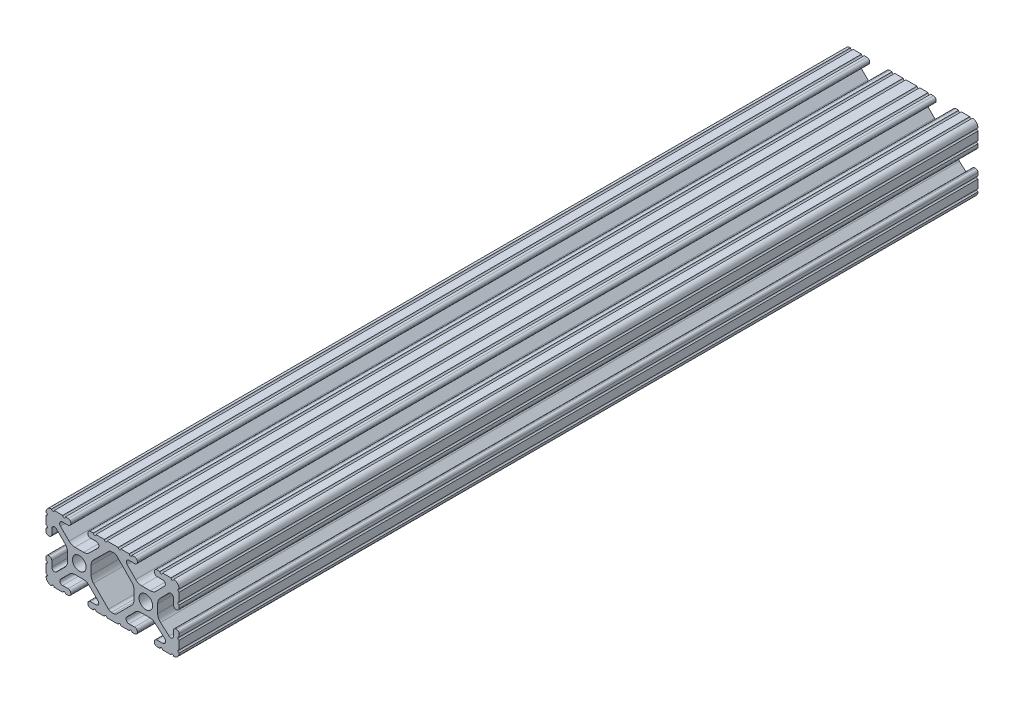
from build123d import *

# Parameters (mm, degrees)
SKETCH1_R           = 2.6035
BOSS_EXTRUDE1_DEPTH = 152.4


with BuildPart() as part:
    # Sketch1 → Boss-Extrude1 (new body, symmetric)
    with BuildSketch(Plane.XY):
        with BuildLine():
            Line((18.01710265, 12.7), (16.98745015, 12.7))
            ThreePointArc((16.98745015, 12.7), (16.245730386, 12.392769614), (15.9385, 11.65104985))
            Line((15.9385, 11.65104985), (15.9385, 11.53922))
            ThreePointArc((15.9385, 11.53922), (16.245750844, 10.797450844), (16.98752, 10.4902))
            Line((16.98752, 10.4902), (19.116384363, 10.4902))
            ThreePointArc((19.116384363, 10.4902), (20.052502933, 9.869096983), (19.844087081, 8.765172272))
            Line((19.844087081, 8.765172272), (16.618993479, 5.455112286))
            ThreePointArc((16.618993479, 5.455112286), (15.578994274, 4.745442459), (14.344932584, 4.4958))
            Line((14.344932584, 4.4958), (11.083317835, 4.4958))
            ThreePointArc((11.083317835, 4.4958), (9.854330953, 4.743306833), (8.816955189, 5.447238587))
            Line((8.816955189, 5.447238587), (5.564154119, 8.762652677))
            ThreePointArc((5.564154119, 8.762652677), (5.352591412, 9.867473037), (6.289393385, 10.4902))
            Line((6.289393385, 10.4902), (8.41248, 10.4902))
            ThreePointArc((8.41248, 10.4902), (9.154249156, 10.797450844), (9.4615, 11.53922))
            Line((9.4615, 11.53922), (9.4615, 11.65104985))
            ThreePointArc((9.4615, 11.65104985), (9.154269614, 12.392769614), (8.41254985, 12.7))
            Line((8.41254985, 12.7), (7.38288465, 12.7))
            ThreePointArc((7.38288465, 12.7), (6.87488465, 12.192), (6.36688465, 12.7))
            Line((6.36688465, 12.7), (3.14958095, 12.7))
            ThreePointArc((3.14958095, 12.7), (2.64158095, 12.192), (2.13358095, 12.7))
            Line((2.13358095, 12.7), (-2.13358095, 12.7))
            ThreePointArc((-2.13358095, 12.7), (-2.64158095, 12.192), (-3.14958095, 12.7))
            Line((-3.14958095, 12.7), (-6.36689735, 12.7))
            ThreePointArc((-6.36689735, 12.7), (-6.87489735, 12.192), (-7.38289735, 12.7))
            Line((-7.38289735, 12.7), (-8.41254985, 12.7))
            ThreePointArc((-8.41254985, 12.7), (-9.154269614, 12.392769614), (-9.4615, 11.65104985))
            Line((-9.4615, 11.65104985), (-9.4615, 11.53922))
            ThreePointArc((-9.4615, 11.53922), (-9.154249156, 10.797450844), (-8.41248, 10.4902))
            Line((-8.41248, 10.4902), (-6.283641037, 10.4902))
            ThreePointArc((-6.283641037, 10.4902), (-5.297291557, 9.829633109), (-5.532576693, 8.666071843))
            Line((-5.532576693, 8.666071843), (-8.809985098, 5.416263103))
            ThreePointArc((-8.809985098, 5.416263103), (-9.836720513, 4.734920264), (-11.045536121, 4.4958))
            Line((-11.045536121, 4.4958), (-14.354463879, 4.4958))
            ThreePointArc((-14.354463879, 4.4958), (-15.563279487, 4.734920264), (-16.590014902, 5.416263103))
            Line((-16.590014902, 5.416263103), (-19.867423307, 8.666071843))
            ThreePointArc((-19.867423307, 8.666071843), (-20.102708443, 9.829633109), (-19.116358963, 10.4902))
            Line((-19.116358963, 10.4902), (-16.98752, 10.4902))
            ThreePointArc((-16.98752, 10.4902), (-16.245750844, 10.797450844), (-15.9385, 11.53922))
            Line((-15.9385, 11.53922), (-15.9385, 11.65104985))
            ThreePointArc((-15.9385, 11.65104985), (-16.245730386, 12.392769614), (-16.98745015, 12.7))
            Line((-16.98745015, 12.7), (-18.01711535, 12.7))
            ThreePointArc((-18.01711535, 12.7), (-18.52511535, 12.192), (-19.03311535, 12.7))
            Line((-19.03311535, 12.7), (-22.2504, 12.7))
            ThreePointArc((-22.2504, 12.7), (-22.758323491, 12.192000006), (-23.266399977, 12.699846982))
            ThreePointArc((-23.266399977, 12.699846982), (-24.782522516, 12.082522516), (-25.399846982, 10.566399977))
            ThreePointArc((-25.399846982, 10.566399977), (-24.892000006, 10.058323491), (-25.4, 9.5504))
            Line((-25.4, 9.5504), (-25.4, 6.3330836))
            ThreePointArc((-25.4, 6.3330836), (-24.892, 5.8250836), (-25.4, 5.3170836))
            Line((-25.4, 5.3170836), (-25.4, 4.237520184))
            ThreePointArc((-25.4, 4.237520184), (-25.107393763, 3.531106237), (-24.400979816, 3.2385))
            Line((-24.400979816, 3.2385), (-24.23922, 3.2385))
            ThreePointArc((-24.23922, 3.2385), (-23.497450844, 3.545750844), (-23.1902, 4.28752))
            Line((-23.1902, 4.28752), (-23.1902, 6.334741132))
            ThreePointArc((-23.1902, 6.334741132), (-22.556026952, 7.286023527), (-21.434002553, 7.066535717))
            Line((-21.434002553, 7.066535717), (-18.147950853, 3.808156468))
            ThreePointArc((-18.147950853, 3.808156468), (-17.452759693, 2.774838327), (-17.208501877, 1.553619571))
            Line((-17.208501877, 1.553619571), (-17.208501877, -1.695179196))
            ThreePointArc((-17.208501877, -1.695179196), (-17.450738657, -2.911536421), (-18.140486065, -3.942289578))
            Line((-18.140486065, -3.942289578), (-21.431579576, -7.227386226))
            ThreePointArc((-21.431579576, -7.227386226), (-22.55444896, -7.449940594), (-23.1902, -6.498002195))
            Line((-23.1902, -6.498002195), (-23.1902, -4.28752))
            ThreePointArc((-23.1902, -4.28752), (-23.497450844, -3.545750844), (-24.23922, -3.2385))
            Line((-24.23922, -3.2385), (-24.35098, -3.2385))
            ThreePointArc((-24.35098, -3.2385), (-25.092749156, -3.545750844), (-25.4, -4.28752))
            Line((-25.4, -4.28752), (-25.4, -5.3171344))
            ThreePointArc((-25.4, -5.3171344), (-24.892, -5.8251344), (-25.4, -6.3331344))
            Line((-25.4, -6.3331344), (-25.4, -9.5504))
            ThreePointArc((-25.4, -9.5504), (-24.892000006, -10.058323491), (-25.399846982, -10.566399977))
            ThreePointArc((-25.399846982, -10.566399977), (-24.782522516, -12.082522516), (-23.266399977, -12.699846982))
            ThreePointArc((-23.266399977, -12.699846982), (-22.758323491, -12.192000006), (-22.2504, -12.7))
            Line((-22.2504, -12.7), (-19.03308995, -12.7))
            ThreePointArc((-19.03308995, -12.7), (-18.52508995, -12.192), (-18.01708995, -12.7))
            Line((-18.01708995, -12.7), (-16.9874692, -12.7))
            ThreePointArc((-16.9874692, -12.7), (-16.245700044, -12.392749156), (-15.9384492, -11.65098))
            Line((-15.9384492, -11.65098), (-15.9384492, -11.53922))
            ThreePointArc((-15.9384492, -11.53922), (-16.245700044, -10.797450844), (-16.9874692, -10.4902))
            Line((-16.9874692, -10.4902), (-19.116358963, -10.4902))
            ThreePointArc((-19.116358963, -10.4902), (-20.055197748, -9.862578342), (-19.834124023, -8.755124678))
            Line((-19.834124023, -8.755124678), (-16.49660751, -5.423689618))
            ThreePointArc((-16.49660751, -5.423689618), (-15.467274017, -4.736928798), (-14.253591699, -4.4958))
            Line((-14.253591699, -4.4958), (-11.146408301, -4.4958))
            ThreePointArc((-11.146408301, -4.4958), (-9.932725983, -4.736928798), (-8.90339249, -5.423689618))
            Line((-8.90339249, -5.423689618), (-5.565875977, -8.755124678))
            ThreePointArc((-5.565875977, -8.755124678), (-5.344802252, -9.862578342), (-6.283641037, -10.4902))
            Line((-6.283641037, -10.4902), (-8.4125308, -10.4902))
            ThreePointArc((-8.4125308, -10.4902), (-9.154299956, -10.797450844), (-9.4615508, -11.53922))
            Line((-9.4615508, -11.53922), (-9.4615508, -11.65098))
            ThreePointArc((-9.4615508, -11.65098), (-9.154299956, -12.392749156), (-8.4125308, -12.7))
            Line((-8.4125308, -12.7), (-7.38287195, -12.7))
            ThreePointArc((-7.38287195, -12.7), (-6.87487195, -12.192), (-6.36687195, -12.7))
            Line((-6.36687195, -12.7), (-3.14960635, -12.7))
            ThreePointArc((-3.14960635, -12.7), (-2.64160635, -12.192), (-2.13360635, -12.7))
            Line((-2.13360635, -12.7), (2.13360635, -12.7))
            ThreePointArc((2.13360635, -12.7), (2.64159365, -12.1920127), (3.14958095, -12.7))
            Line((3.14958095, -12.7), (6.36691005, -12.7))
            ThreePointArc((6.36691005, -12.7), (6.87491005, -12.192), (7.38291005, -12.7))
            Line((7.38291005, -12.7), (8.4125308, -12.7))
            ThreePointArc((8.4125308, -12.7), (9.154299956, -12.392749156), (9.4615508, -11.65098))
            Line((9.4615508, -11.65098), (9.4615508, -11.53922))
            ThreePointArc((9.4615508, -11.53922), (9.154299956, -10.797450844), (8.4125308, -10.4902))
            Line((8.4125308, -10.4902), (6.289393385, -10.4902))
            ThreePointArc((6.289393385, -10.4902), (5.231590322, -9.783049717), (5.480677245, -8.535265862))
            Line((5.480677245, -8.535265862), (8.597933595, -5.423689618))
            ThreePointArc((8.597933595, -5.423689618), (9.627267088, -4.736928798), (10.840949406, -4.4958))
            Line((10.840949406, -4.4958), (14.102564155, -4.4958))
            ThreePointArc((14.102564155, -4.4958), (15.215927525, -4.697410182), (16.187895372, -5.276636531))
            Line((16.187895372, -5.276636531), (19.868247549, -8.482246082))
            ThreePointArc((19.868247549, -8.482246082), (20.188435806, -9.746879864), (19.116384363, -10.4902))
            Line((19.116384363, -10.4902), (16.9874692, -10.4902))
            ThreePointArc((16.9874692, -10.4902), (16.245700044, -10.797450844), (15.9384492, -11.53922))
            Line((15.9384492, -11.53922), (15.9384492, -11.65098))
            ThreePointArc((15.9384492, -11.65098), (16.245700044, -12.392749156), (16.9874692, -12.7))
            Line((16.9874692, -12.7), (18.01710265, -12.7))
            ThreePointArc((18.01710265, -12.7), (18.52510265, -12.192), (19.03310265, -12.7))
            Line((19.03310265, -12.7), (22.2504, -12.7))
            ThreePointArc((22.2504, -12.7), (22.758323491, -12.192000006), (23.266399977, -12.699846982))
            ThreePointArc((23.266399977, -12.699846982), (24.782522516, -12.082522516), (25.399846982, -10.566399977))
            ThreePointArc((25.399846982, -10.566399977), (24.892000006, -10.058323492), (25.4, -9.550400001))
            Line((25.4, -9.550400001), (25.4, -6.333083592))
            ThreePointArc((25.4, -6.333083592), (24.892000001, -5.825083593), (25.4, -5.317083593))
            Line((25.4, -5.317083593), (25.4, -4.237520184))
            ThreePointArc((25.4, -4.237520184), (25.107393763, -3.531106237), (24.400979816, -3.2385))
            Line((24.400979816, -3.2385), (24.189220184, -3.2385))
            ThreePointArc((24.189220184, -3.2385), (23.482806237, -3.531106237), (23.1902, -4.237520184))
            Line((23.1902, -4.237520184), (23.1902, -6.155876159))
            ThreePointArc((23.1902, -6.155876159), (22.62232736, -7.038258539), (21.583974541, -6.886926384))
            Line((21.583974541, -6.886926384), (18.29817066, -4.024970844))
            ThreePointArc((18.29817066, -4.024970844), (17.493730985, -2.946044689), (17.208501877, -1.630807374))
            Line((17.208501877, -1.630807374), (17.208501877, 1.630807374))
            ThreePointArc((17.208501877, 1.630807374), (17.442348332, 2.82673414), (18.109440981, 3.846495088))
            Line((18.109440981, 3.846495088), (21.526346532, 7.353420386))
            ThreePointArc((21.526346532, 7.353420386), (22.585896263, 7.574939077), (23.1902, 6.676867167))
            Line((23.1902, 6.676867167), (23.1902, 4.237520184))
            ThreePointArc((23.1902, 4.237520184), (23.482806237, 3.531106237), (24.189220184, 3.2385))
            Line((24.189220184, 3.2385), (24.400979816, 3.2385))
            ThreePointArc((24.400979816, 3.2385), (25.107393763, 3.531106237), (25.4, 4.237520184))
            Line((25.4, 4.237520184), (25.4, 5.3170836))
            ThreePointArc((25.4, 5.3170836), (24.891949193, 5.825134407), (25.4, 6.333185215))
            Line((25.4, 6.333185215), (25.4, 9.550400015))
            ThreePointArc((25.4, 9.550400015), (24.892000013, 10.058323498), (25.399846982, 10.566399977))
            ThreePointArc((25.399846982, 10.566399977), (24.782522516, 12.082522516), (23.266399977, 12.699846982))
            ThreePointArc((23.266399977, 12.699846982), (22.758323491, 12.192000006), (22.2504, 12.7))
            Line((22.2504, 12.7), (19.03310265, 12.7))
            ThreePointArc((19.03310265, 12.7), (18.52510265, 12.192), (18.01710265, 12.7))
        make_face()
        with Locations((-12.7, 0)):
            Circle(SKETCH1_R, mode=Mode.SUBTRACT)
        with Locations((12.7, 0)):
            Circle(SKETCH1_R, mode=Mode.SUBTRACT)
        with BuildLine():
            Line((-7.259513935, -3.869413038), (-1.545748891, -9.572766749))
            ThreePointArc((-1.545748891, -9.572766749), (-1.035199478, -9.913400116), (-0.433213048, -10.033))
            Line((-0.433213048, -10.033), (0.433213048, -10.033))
            ThreePointArc((0.433213048, -10.033), (1.035199478, -9.913400116), (1.545748891, -9.572766749))
            Line((1.545748891, -9.572766749), (7.259513935, -3.869413038))
            ThreePointArc((7.259513935, -3.869413038), (7.949261343, -2.838659881), (8.191498123, -1.622302656))
            Line((8.191498123, -1.622302656), (8.191498123, 1.622302656))
            ThreePointArc((8.191498123, 1.622302656), (7.955573352, 2.823327967), (7.282860769, 3.845864069))
            Line((7.282860769, 3.845864069), (1.675572808, 9.561086461))
            ThreePointArc((1.675572808, 9.561086461), (1.161034429, 9.910236611), (0.551456936, 10.033))
            Line((0.551456936, 10.033), (-0.395199982, 10.033))
            ThreePointArc((-0.395199982, 10.033), (-0.994772524, 9.914396349), (-1.50403329, 9.576450301))
            Line((-1.50403329, 9.576450301), (-7.252049147, 3.876839553))
            ThreePointArc((-7.252049147, 3.876839553), (-7.947240307, 2.843521412), (-8.191498123, 1.622302656))
            Line((-8.191498123, 1.622302656), (-8.191498123, -1.622302656))
            ThreePointArc((-8.191498123, -1.622302656), (-7.949261343, -2.838659881), (-7.259513935, -3.869413038))
        make_face(mode=Mode.SUBTRACT)
    extrude(amount=BOSS_EXTRUDE1_DEPTH, both=True)


solid = part.part
